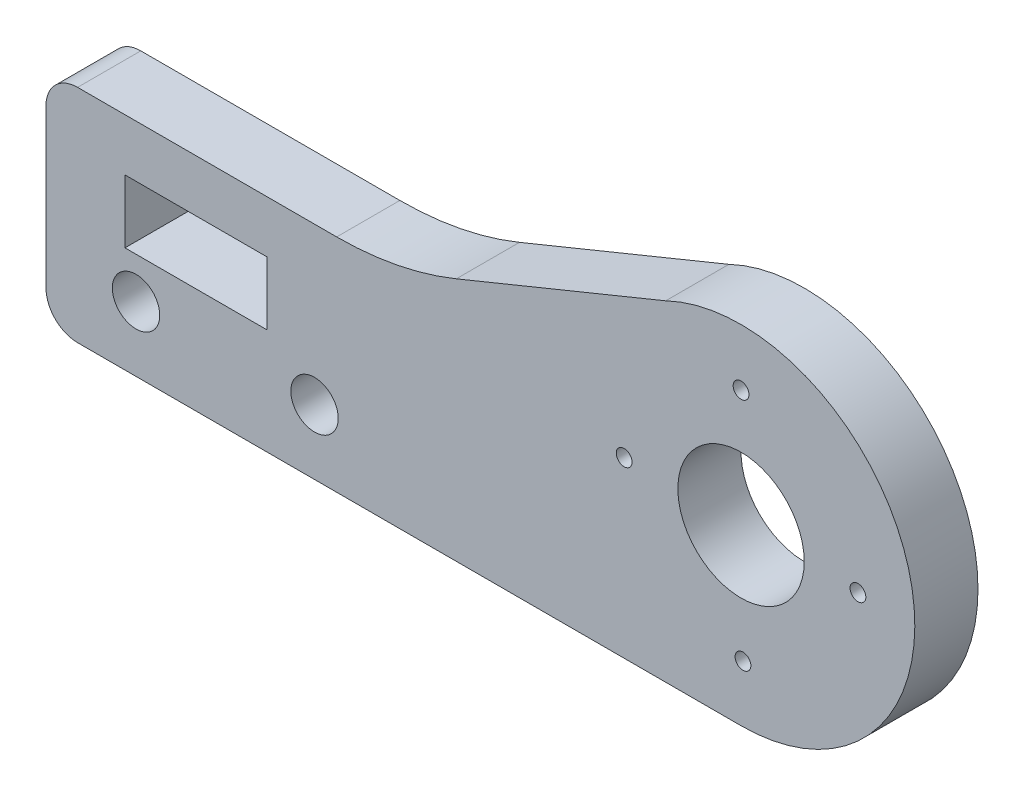
from build123d import *

# Parameters (mm, degrees)
SKETCH1_R           = 4
SKETCH1_R_2         = 0.5
SKETCH1_R_3         = 1.5
SKETCH1_W           = 9
SKETCH1_H           = 4
BOSS_EXTRUDE1_DEPTH = 4


with BuildPart() as part:
    # Sketch1 → Boss-Extrude1 (new body)
    with BuildSketch(Plane.XY):
        with BuildLine():
            Line((2, 2), (2, 12))
            ThreePointArc((2, 12), (2.585786438, 13.414213562), (4, 14))
            Line((4, 14), (20.401115249, 14))
            ThreePointArc((20.401115249, 14), (24.259789892, 14.375764219), (27.973469349, 15.488937))
            Line((27.973469349, 15.488937), (41.227821741, 20.910918962))
            ThreePointArc((41.227821741, 20.910918962), (56.724274068, 13.447436559), (46, 0))
            Line((46, 0), (4, 0))
            ThreePointArc((4, 0), (2.585786438, 0.585786438), (2, 2))
        make_face()
        with Locations((46, 11)):
            Circle(SKETCH1_R, mode=Mode.SUBTRACT)
        with Locations((46, 18.4)):
            Circle(SKETCH1_R_2, mode=Mode.SUBTRACT)
        with Locations((46.121025162, 3.600989734)):
            Circle(SKETCH1_R_2, mode=Mode.SUBTRACT)
        with Locations((53.4, 11)):
            Circle(SKETCH1_R_2, mode=Mode.SUBTRACT)
        with Locations((38.6, 11)):
            Circle(SKETCH1_R_2, mode=Mode.SUBTRACT)
        with Locations((19, 4.1)):
            Circle(SKETCH1_R_3, mode=Mode.SUBTRACT)
        with Locations((7.7, 4.1)):
            Circle(SKETCH1_R_3, mode=Mode.SUBTRACT)
        with Locations((11.5, 8.7)):
            Rectangle(SKETCH1_W, SKETCH1_H, mode=Mode.SUBTRACT)
    extrude(amount=BOSS_EXTRUDE1_DEPTH)


solid = part.part
